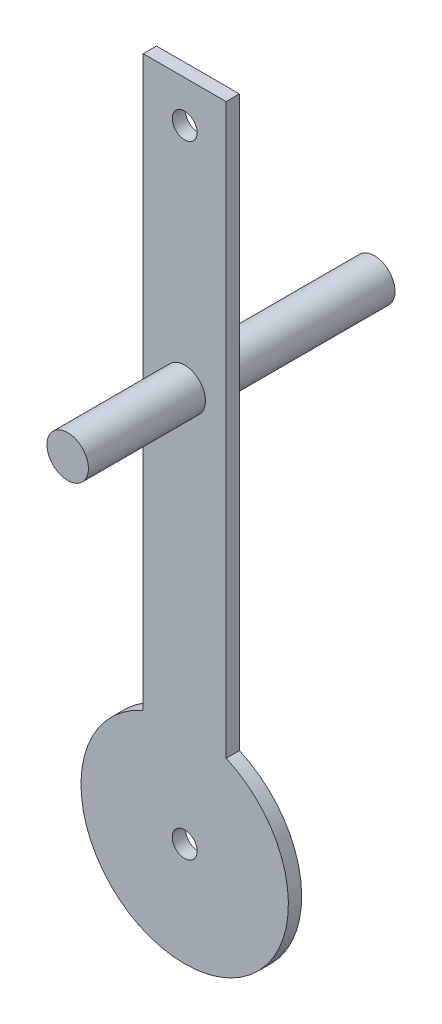
from build123d import *

# Parameters (mm, degrees)
SKETCH1_R           = 1.5
BOSS_EXTRUDE1_DEPTH = 1.6
SKETCH2_R           = 1.5
CUT_EXTRUDE1_DEPTH  = 2.6
SKETCH3_R           = 2.5
BOSS_EXTRUDE2_DEPTH = 14.1
SKETCH4_R           = 2.5
BOSS_EXTRUDE3_DEPTH = 21.25


with BuildPart() as part:
    # Sketch1 → Boss-Extrude1 (new body)
    with BuildSketch(Plane.XY):
        with BuildLine():
            Line((0, 0), (0, 68.543560763))
            Line((0, 68.543560763), (10, 68.543560763))
            Line((10, 68.543560763), (10, 0))
            ThreePointArc((10, 0), (5, -23.956439237), (0, 0))
        make_face()
        with Locations((5, -11.456439237)):
            Circle(SKETCH1_R, mode=Mode.SUBTRACT)
    extrude(amount=BOSS_EXTRUDE1_DEPTH)

    # Sketch2 → Cut-Extrude1 (cut, through all)
    with BuildSketch(Plane.XY.offset(1.6)):
        with Locations((5, 63.543560763)):
            Circle(SKETCH2_R)
    extrude(amount=-CUT_EXTRUDE1_DEPTH, mode=Mode.SUBTRACT)

    # Sketch3 → Boss-Extrude2 (add)
    with BuildSketch(Plane.XY.offset(1.6)):
        with Locations((5, 36.043560763)):
            Circle(SKETCH3_R)
    extrude(amount=BOSS_EXTRUDE2_DEPTH)

    # Sketch4 → Boss-Extrude3 (add)
    with BuildSketch(Plane(origin=(0, 0, 0), x_dir=(-1, 0, 0), z_dir=(0, 0, -1))):
        with Locations((-5, 36.043560763)):
            Circle(SKETCH4_R)
    extrude(amount=BOSS_EXTRUDE3_DEPTH)


solid = part.part
